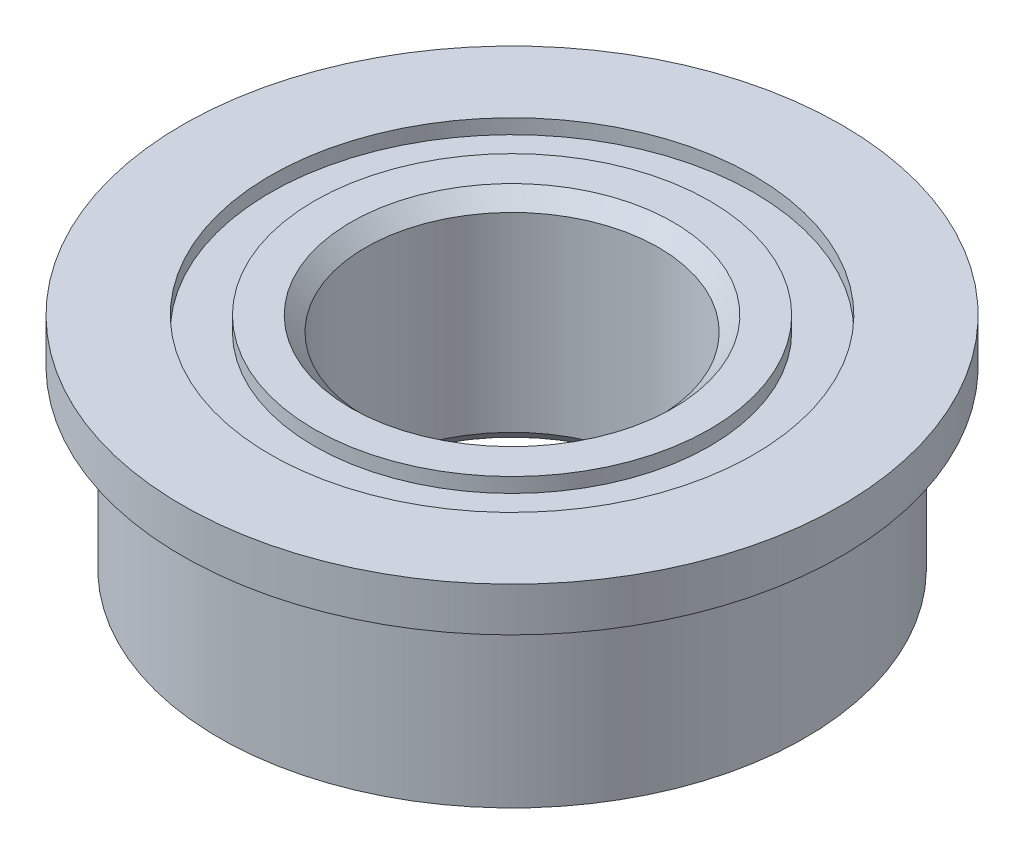
from build123d import *

# Parameters (mm, degrees)
CHAMFER1_SIZE = 0.2


with BuildPart() as part:
    # Sketch1 → Revolve1 (revolve)
    with BuildSketch(Plane.XY):
        Polygon((2, -2.4), (2, 0.6), (2.7, 0.6), (2.7, 0.4), (3.3, 0.4), (3.3, 0.6), (4.5, 0.6), (4.5, 0), (4, 0), (4, -2.4), (3.3, -2.4), (3.3, -2.2), (2.7, -2.2), (2.7, -2.4), align=None)
    revolve(axis=Axis((0, 0, 0), (0, 1, 0)))

    # Chamfer1
    chamfer1_edges = [part.edges().sort_by_distance(p)[0] for p in [
        (-2, -2.4, 0),
        (-2, 0.6, 0),
    ]]
    chamfer(chamfer1_edges, length=CHAMFER1_SIZE)


solid = part.part
